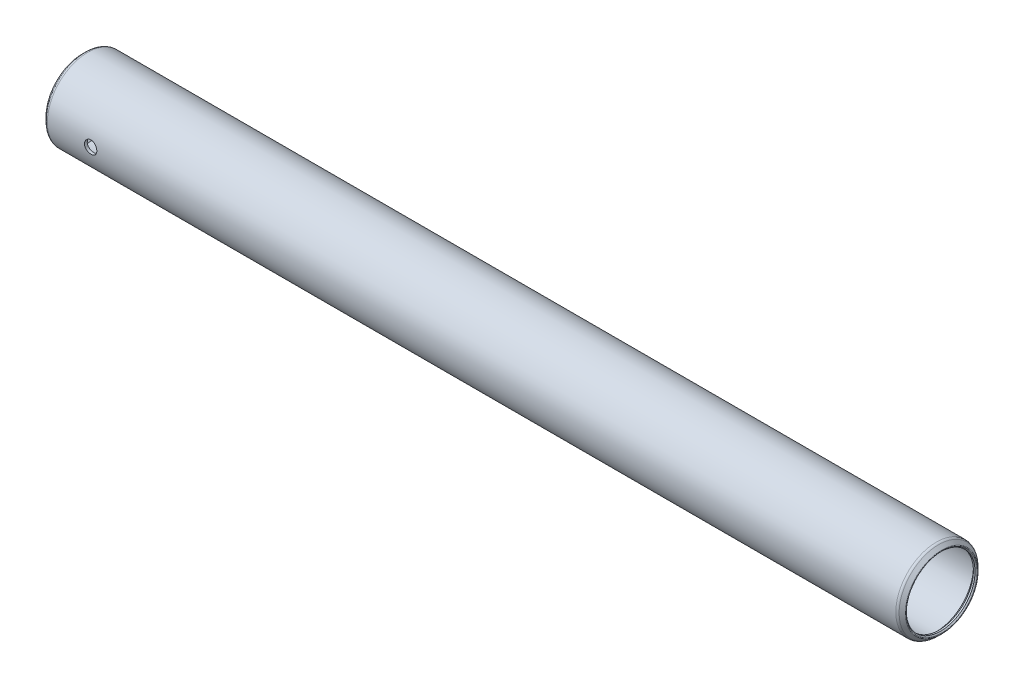
from build123d import *

# Parameters (mm, degrees)
SKETCH2_R          = 1.1938
CUT_EXTRUDE1_DEPTH = 7.8105


with BuildPart() as part:
    # Sketch1 → Revolve1 (revolve)
    with BuildSketch(Plane.XY):
        with BuildLine():
            Line((-0.517960245, 6.836210245), (-0.3175, 6.63575))
            Line((-0.3175, 6.63575), (0, 6.63575))
            Line((0, 6.63575), (0.635, 7.27075))
            Line((0.635, 7.27075), (164.2364, 7.27075))
            Line((164.2364, 7.27075), (164.8714, 6.63575))
            Line((164.8714, 6.63575), (165.1889, 6.63575))
            Line((165.1889, 6.63575), (165.389360245, 6.836210245))
            ThreePointArc((165.389360245, 6.836210245), (165.426557684, 6.926012806), (165.389360245, 7.015815367))
            Line((165.389360245, 7.015815367), (164.780662806, 7.624512806))
            ThreePointArc((164.780662806, 7.624512806), (164.57465398, 7.762163503), (164.33165, 7.8105))
            Line((164.33165, 7.8105), (0.53975, 7.8105))
            ThreePointArc((0.53975, 7.8105), (0.29674602, 7.762163503), (0.090737194, 7.624512806))
            Line((0.090737194, 7.624512806), (-0.517960245, 7.015815367))
            ThreePointArc((-0.517960245, 7.015815367), (-0.555157684, 6.926012806), (-0.517960245, 6.836210245))
        make_face()
    revolve(axis=Axis((164.8714, 0, 0), (-1, 0, 0)))

    # Sketch2 → Cut-Extrude1 (cut)
    with BuildSketch(Plane.XY):
        with Locations((8.89, 0)):
            Circle(SKETCH2_R)
    extrude(amount=CUT_EXTRUDE1_DEPTH, mode=Mode.SUBTRACT)


solid = part.part
